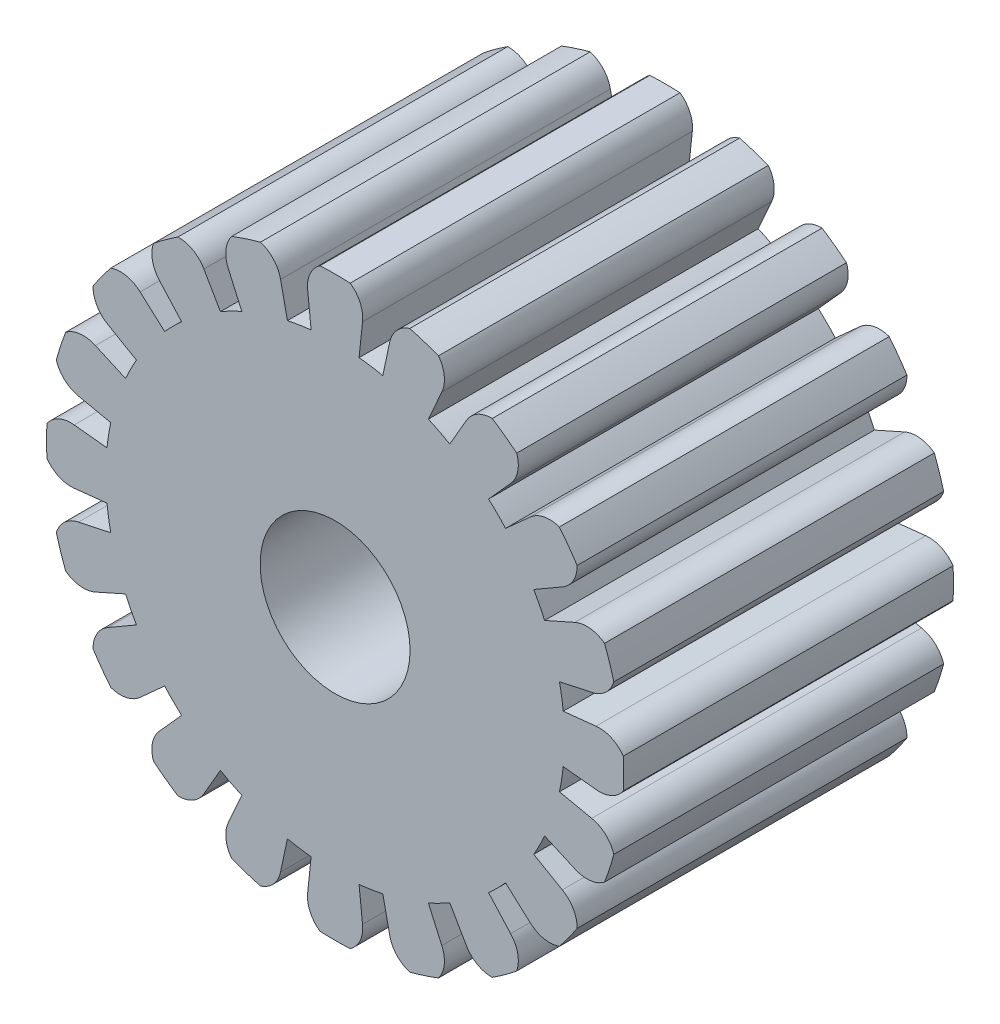
from build123d import *

# Parameters (mm, degrees)
BOSS_EXTRUDE3_DEPTH     = 22
CIRPATTERN3_COUNT       = 20
SKETCH2_R               = 10
CUT_EXTRUDE1_DEPTH      = 23
CUT_EXTRUDE1_DEPTH_BACK = 23


with BuildPart() as part:
    # Sketch1 → Boss-Extrude3 (new body, symmetric)
    with BuildSketch(Plane.XY):
        with BuildLine():
            Line((34.808266338, 3.658496214), (30.432369998, 3.198570976))
            ThreePointArc((30.432369998, 3.198570976), (30.338212758, 3.994101482), (30.223263222, 4.78689463))
            Line((30.223263222, 4.78689463), (0, 0))
            Line((0, 0), (30.223263222, -4.78689463))
            ThreePointArc((30.223263222, -4.78689463), (30.338212758, -3.994101482), (30.432369998, -3.198570976))
            Line((30.432369998, -3.198570976), (34.808266338, -3.658496214))
            ThreePointArc((34.808266338, -3.658496214), (36.855171385, -3.340239675), (38.447237088, -2.014934315))
            ThreePointArc((38.447237088, -2.014934315), (38.5, 0), (38.447237088, 2.014934315))
            ThreePointArc((38.447237088, 2.014934315), (36.855171385, 3.340239675), (34.808266338, 3.658496214))
        make_face()
    boss_extrude3 = extrude(amount=BOSS_EXTRUDE3_DEPTH, both=True)

    # CirPattern3: Boss-Extrude3 ×20 about axis
    cirpattern3_axis = Axis((0, 0, 0), (0, 0, 1))
    for i in range(1, CIRPATTERN3_COUNT):
        add(boss_extrude3.rotate(cirpattern3_axis, i * 360 / CIRPATTERN3_COUNT))

    # Sketch2 → Cut-Extrude1 (cut, two sides)
    with BuildSketch(Plane.XY) as cut_extrude1_sk:
        Circle(SKETCH2_R)
    extrude(amount=CUT_EXTRUDE1_DEPTH, mode=Mode.SUBTRACT)
    extrude(cut_extrude1_sk.sketch, amount=-CUT_EXTRUDE1_DEPTH_BACK, mode=Mode.SUBTRACT)


solid = part.part
